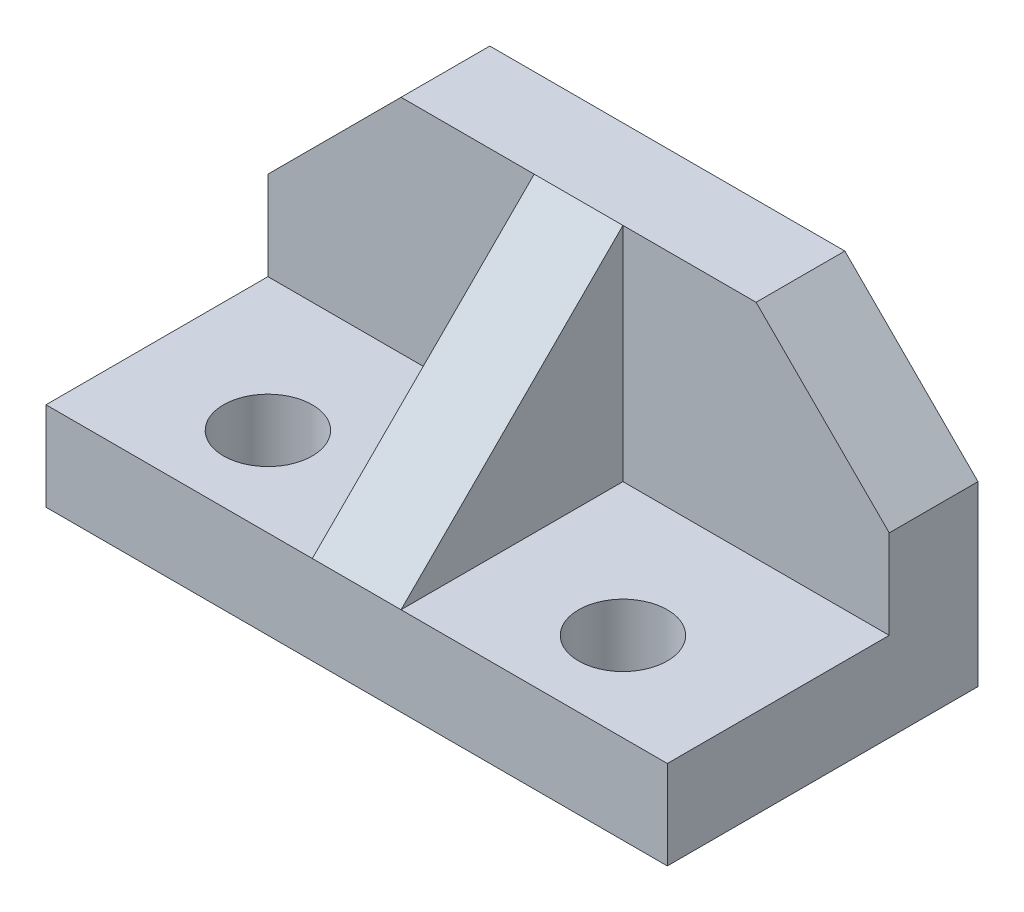
from build123d import *

# Parameters (mm, degrees)
SKETCH2_W           = 70
SKETCH2_H           = 35
BOSS_EXTRUDE1_DEPTH = 35
SKETCH3_W           = 30
SKETCH3_H           = 25
CUT_EXTRUDE1_DEPTH  = 25
SKETCH4_W           = 30
SKETCH4_H           = 25
CUT_EXTRUDE2_DEPTH  = 25
CUT_EXTRUDE3_DEPTH  = 25
CUT_EXTRUDE4_DEPTH  = 25
CUT_EXTRUDE5_DEPTH  = 25
SKETCH8_R           = 5
CUT_EXTRUDE6_DEPTH  = 11
SKETCH9_R           = 5
CUT_EXTRUDE7_DEPTH  = 11


with BuildPart() as part:
    # Sketch2 → Boss-Extrude1 (new body)
    with BuildSketch(Plane(origin=(0, 0, 0), x_dir=(1, 0, 0), z_dir=(0, 1, 0))):
        with Locations((35, 17.5)):
            Rectangle(SKETCH2_W, SKETCH2_H)
    extrude(amount=BOSS_EXTRUDE1_DEPTH)

    # Sketch3 → Cut-Extrude1 (cut)
    with BuildSketch(Plane.XY):
        with Locations((55, 22.5)):
            Rectangle(SKETCH3_W, SKETCH3_H)
    extrude(amount=-CUT_EXTRUDE1_DEPTH, mode=Mode.SUBTRACT)

    # Sketch4 → Cut-Extrude2 (cut)
    with BuildSketch(Plane.XY):
        with Locations((15, 22.5)):
            Rectangle(SKETCH4_W, SKETCH4_H)
    extrude(amount=-CUT_EXTRUDE2_DEPTH, mode=Mode.SUBTRACT)

    # Sketch5 → Cut-Extrude3 (cut)
    with BuildSketch(Plane(origin=(40, 0, 0), x_dir=(0, 0, -1), z_dir=(1, 0, 0))):
        Polygon((0, 10), (25, 35), (0, 35), align=None)
    extrude(amount=-CUT_EXTRUDE3_DEPTH, mode=Mode.SUBTRACT)

    # Sketch6 → Cut-Extrude4 (cut)
    with BuildSketch(Plane.XY.offset(-25)):
        Polygon((70, 35), (70, 20), (55, 35), align=None)
    extrude(amount=-CUT_EXTRUDE4_DEPTH, mode=Mode.SUBTRACT)

    # Sketch7 → Cut-Extrude5 (cut)
    with BuildSketch(Plane.XY.offset(-25)):
        Polygon((0, 35), (0, 20), (15, 35), align=None)
    extrude(amount=-CUT_EXTRUDE5_DEPTH, mode=Mode.SUBTRACT)

    # Sketch8 → Cut-Extrude6 (cut, through all)
    with BuildSketch(Plane(origin=(0, 10, 0), x_dir=(1, 0, 0), z_dir=(0, 1, 0))):
        with Locations((55, 10)):
            Circle(SKETCH8_R)
    extrude(amount=-CUT_EXTRUDE6_DEPTH, mode=Mode.SUBTRACT)

    # Sketch9 → Cut-Extrude7 (cut, through all)
    with BuildSketch(Plane(origin=(0, 10, 0), x_dir=(1, 0, 0), z_dir=(0, 1, 0))):
        with Locations((15, 10)):
            Circle(SKETCH9_R)
    extrude(amount=-CUT_EXTRUDE7_DEPTH, mode=Mode.SUBTRACT)


solid = part.part
